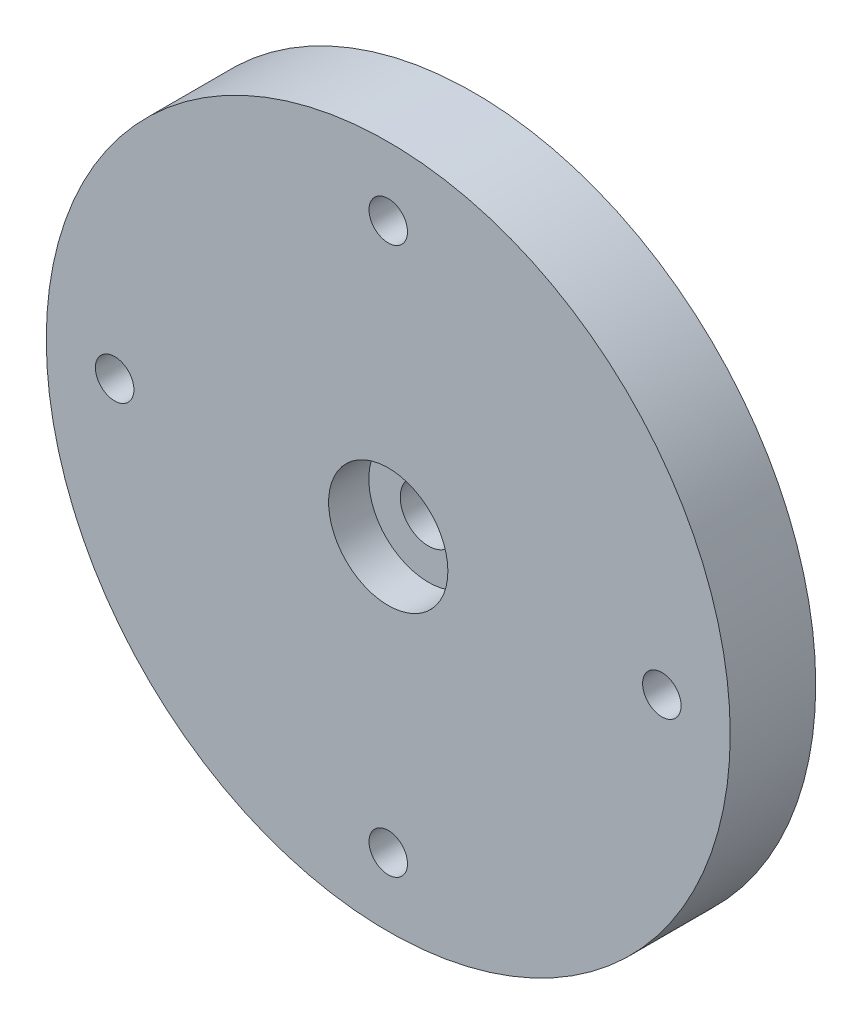
from build123d import *

# Parameters (mm, degrees)
SKETCH1_R                                        = 40
BOSS_EXTRUDE1_DEPTH                              = 10
CBORE_FOR_M6_HEX_HEAD_MACHINE_SCREW1_D           = 6.6
CBORE_FOR_M6_HEX_HEAD_MACHINE_SCREW1_CBORE_D     = 13.95
CBORE_FOR_M6_HEX_HEAD_MACHINE_SCREW1_CBORE_DEPTH = 4.7
M4_CLEARANCE_HOLE1_D                             = 4.5
SKETCH6_R                                        = 8.5
CUT_EXTRUDE1_DEPTH                               = 2


with BuildPart() as part:
    # Sketch1 → Boss-Extrude1 (new body)
    with BuildSketch(Plane.XY):
        Circle(SKETCH1_R)
    extrude(amount=BOSS_EXTRUDE1_DEPTH)

    # CBORE for M6 Hex Head Machine Screw1 (through all)
    with Locations(Plane.XY.offset(10)):
        with Locations((0, 0)):
            CounterBoreHole(CBORE_FOR_M6_HEX_HEAD_MACHINE_SCREW1_D / 2, CBORE_FOR_M6_HEX_HEAD_MACHINE_SCREW1_CBORE_D / 2, CBORE_FOR_M6_HEX_HEAD_MACHINE_SCREW1_CBORE_DEPTH)

    # M4 Clearance Hole1 (through all)
    with Locations(Plane.XY.offset(10)):
        with Locations((0, 32), (32, 0), (0, -32), (-32, 0)):
            Hole(M4_CLEARANCE_HOLE1_D / 2)

    # Sketch6 → Cut-Extrude1 (cut)
    with BuildSketch(Plane(origin=(0, 0, 0), x_dir=(-1, 0, 0), z_dir=(0, 0, -1))):
        Circle(SKETCH6_R)
    extrude(amount=-CUT_EXTRUDE1_DEPTH, mode=Mode.SUBTRACT)


solid = part.part
